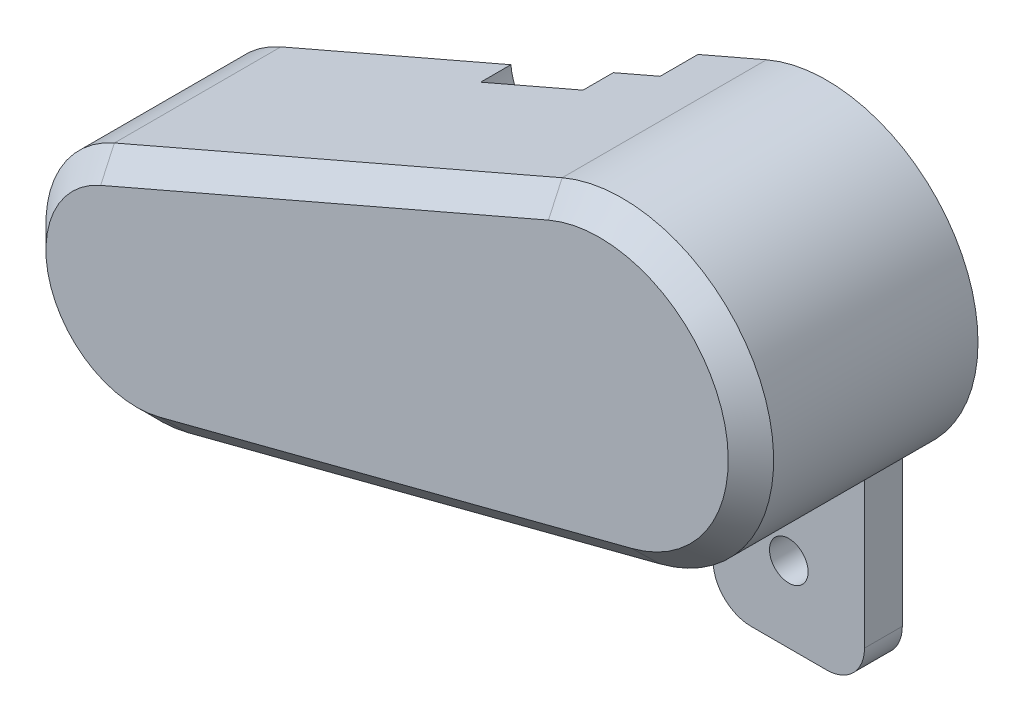
from build123d import *

# Parameters (mm, degrees)
BOSS_EXTRUDE1_DEPTH = 3
BOSS_EXTRUDE2_DEPTH = 26.999994
CHAMFER1_SIZE       = 3
CUT_EXTRUDE1_DEPTH  = 4.999994
SKETCH4_3_R         = 7.75
CUT_EXTRUDE2_DEPTH  = 4
SKETCH7_R           = 2.55
BOSS_EXTRUDE5_DEPTH = 5


with BuildPart() as part:
    # Sketch2 → Boss-Extrude1 (new body)
    with BuildSketch(Plane.XY.offset(26.999993563)):
        with BuildLine():
            Line((-48.107762328, -39.75057759), (11.056310458, -14.145221365))
            ThreePointArc((11.056310458, -14.145221365), (37.914072471, -25.999413947), (24.018554683, -51.86011478))
            Line((24.018554683, -51.86011478), (-38.38607916, -68.036747651))
            ThreePointArc((-38.38607916, -68.036747651), (-56.335559182, -58.392101106), (-48.107762328, -39.75057759))
        make_face()
    extrude(amount=BOSS_EXTRUDE1_DEPTH)

    # Sketch3 → Boss-Extrude2 (add)
    with BuildSketch(Plane(origin=(0, 0, 26.999993563), x_dir=(-1, 0, 0), z_dir=(0, 0, -1))):
        with BuildLine():
            Line((48.107762328, -39.75057759), (-11.056310458, -14.145221365))
            ThreePointArc((-11.056310458, -14.145221365), (-37.914072471, -25.999413947), (-24.018554683, -51.86011478))
            Line((-24.018554683, -51.86011478), (38.38607916, -68.036747651))
            ThreePointArc((38.38607916, -68.036747651), (56.335559182, -58.392101106), (48.107762328, -39.75057759))
        make_face()
        with BuildLine():
            Line((46.916209863, -42.503794385), (-12.247862924, -16.89843816))
            ThreePointArc((-12.247862924, -16.89843816), (-35.076960635, -26.974501855), (-23.265770515, -48.956097563))
            Line((-23.265770515, -48.956097563), (39.138863328, -65.132730434))
            ThreePointArc((39.138863328, -65.132730434), (53.498447346, -57.417013198), (46.916209863, -42.503794385))
        make_face(mode=Mode.SUBTRACT)
    extrude(amount=BOSS_EXTRUDE2_DEPTH)

    # Chamfer1
    chamfer1_edges = [part.edges().sort_by_distance(p)[0] for p in [
        (37.914072471, -25.999413947, 29.999993563),
        (-18.525725935, -26.947899478, 29.999993563),
        (-53.498447346, -57.417013198, 26.999993563),
        (-17.334173469, -29.701116273, 26.999993563),
        (35.076960635, -26.974501855, 26.999993563),
        (-7.936546407, -57.044413998, 26.999993563),
        (-56.335559182, -58.392101106, 29.999993563),
        (-7.183762238, -59.948431215, 29.999993563),
    ]]
    chamfer(chamfer1_edges, length=CHAMFER1_SIZE)

    # Sketch4 → Cut-Extrude1 (cut)
    with BuildSketch(Plane.XY.offset(4.999993563)):
        Polygon((-63.676072098, -10.5), (2, -10.5), (2, -39.366661566), (-18, -39.366661566), (-18, -71.666661566), (-63.676072098, -71.666661566), align=None)
    extrude(amount=-CUT_EXTRUDE1_DEPTH, mode=Mode.SUBTRACT)

    # Sketch4_3 → Cut-Extrude2 (cut)
    with BuildSketch(Plane.XY.offset(4.999993563)):
        with Locations((-10, -25.866661566)):
            Circle(SKETCH4_3_R)
    extrude(amount=CUT_EXTRUDE2_DEPTH, mode=Mode.SUBTRACT)

    # Sketch7 → Boss-Extrude5 (add)
    with BuildSketch(Plane(origin=(0, 0, 0), x_dir=(-1, 0, 0), z_dir=(0, 0, -1))):
        with BuildLine():
            Line((-8.999993562, -55.753251147), (-8.999993562, -70))
            ThreePointArc((-8.999993562, -70), (-10.464459657, -73.535533906), (-13.999993562, -75))
            Line((-13.999993562, -75), (-23.999993562, -75))
            ThreePointArc((-23.999993562, -75), (-27.535527468, -73.535533906), (-28.999993562, -70))
            Line((-28.999993562, -70), (-28.999993562, -49.820508076))
            ThreePointArc((-28.999993562, -49.820508076), (-26.578205318, -51.008665716), (-24.018554683, -51.86011478))
            Line((-24.018554683, -51.86011478), (-8.999993562, -55.753251147))
        make_face()
        with Locations((-18.999993562, -65)):
            Circle(SKETCH7_R, mode=Mode.SUBTRACT)
    extrude(amount=-BOSS_EXTRUDE5_DEPTH)


solid = part.part
